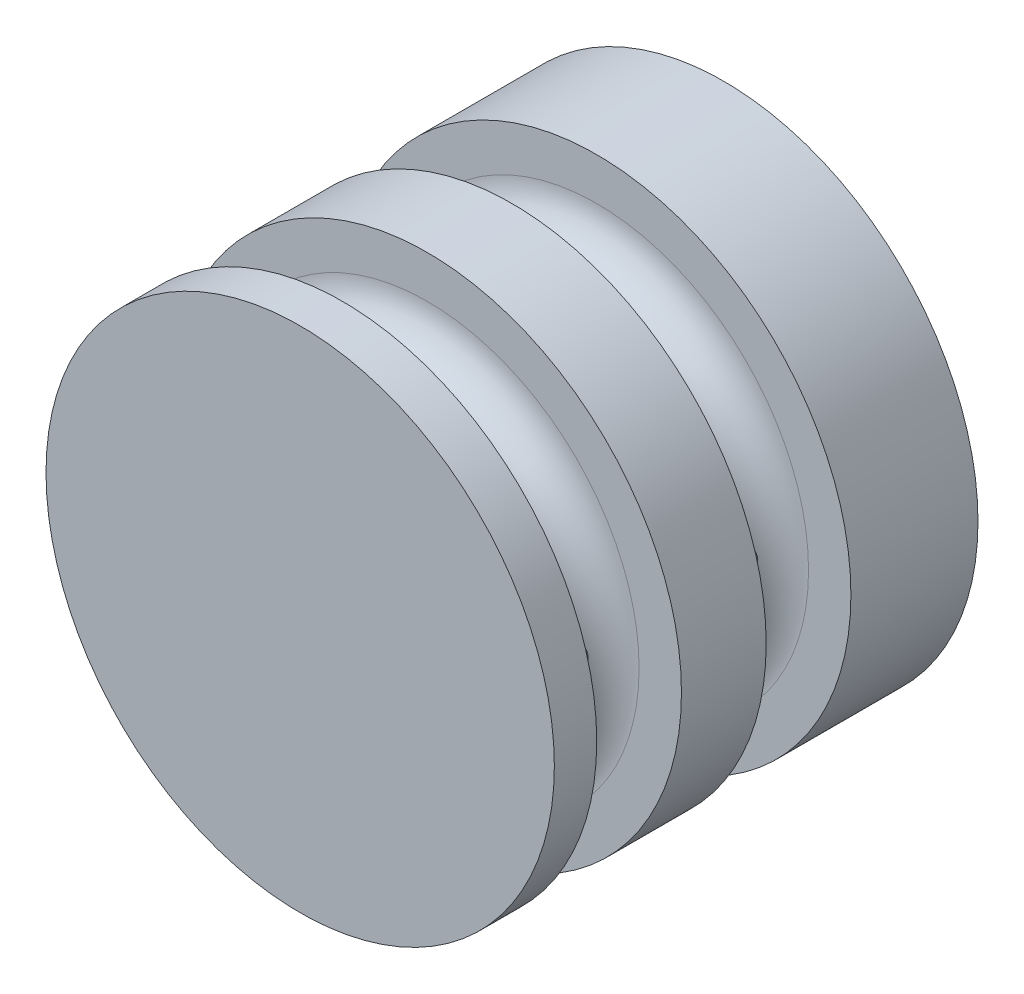
from build123d import *

# Parameters (mm, degrees)
SKETCH2_ONE_SIDE_W       = 5
SKETCH2_ONE_SIDE_H       = 15
SKETCH2_6_R              = 1.5
CUT_EXTRUDE1_DEPTH       = 16
CUT_EXTRUDE1_DEPTH_BACK  = 16
M3_CLEARANCE_HOLE1_D     = 3.2
M3_CLEARANCE_HOLE1_DEPTH = 5
M3_CLEARANCE_HOLE1_TIP   = 0.96137699
CUT_EXTRUDE2_START       = -25
SKETCH1_R                = 3.5
CUT_EXTRUDE2_DEPTH       = 5


with BuildPart() as part:
    # Sketch2 one side → Revolve5 (revolve)
    with BuildSketch(Plane(origin=(0, 0, 0), x_dir=(0, 0, -1), z_dir=(1, 0, 0))):
        with BuildLine():
            Line((3.5, 0), (6.5, 0))
            ThreePointArc((6.5, 0), (5, 1.5), (3.5, 0))
        make_face()
        with BuildLine():
            Line((13.5, 0), (16.5, 0))
            ThreePointArc((16.5, 0), (15, 1.5), (13.5, 0))
        make_face()
        with BuildLine():
            Line((2.5, 12.5), (2.5, 15))
            Line((2.5, 15), (0, 15))
            Line((0, 15), (0, 0))
            Line((0, 0), (3.5, 0))
            ThreePointArc((3.5, 0), (5, 1.5), (6.5, 0))
            Line((6.5, 0), (10, 0))
            Line((10, 0), (13.5, 0))
            ThreePointArc((13.5, 0), (15, 1.5), (16.5, 0))
            Line((16.5, 0), (20, 0))
            Line((20, 0), (20, 15))
            Line((20, 15), (17.5, 15))
            Line((17.5, 15), (17.5, 12.5))
            ThreePointArc((17.5, 12.5), (15, 10), (12.5, 12.5))
            Line((12.5, 12.5), (12.5, 15))
            Line((12.5, 15), (7.5, 15))
            Line((7.5, 15), (7.5, 12.5))
            ThreePointArc((7.5, 12.5), (5, 10), (2.5, 12.5))
        make_face()
        with Locations((22.5, 7.5)):
            Rectangle(SKETCH2_ONE_SIDE_W, SKETCH2_ONE_SIDE_H)
    revolve(axis=Axis((0, 0, 0), (0, 0, -1)))

    # Sketch2_6 → Cut-Extrude1 (cut, two sides)
    with BuildSketch(Plane(origin=(0, 0, 0), x_dir=(0, 0, -1), z_dir=(1, 0, 0))) as cut_extrude1_sk:
        with Locations((5, 0)):
            Circle(SKETCH2_6_R)
        with Locations((15, 0)):
            Circle(SKETCH2_6_R)
    extrude(amount=CUT_EXTRUDE1_DEPTH, mode=Mode.SUBTRACT)
    extrude(cut_extrude1_sk.sketch, amount=-CUT_EXTRUDE1_DEPTH_BACK, mode=Mode.SUBTRACT)

    # M3 Clearance Hole1
    with Locations(Plane(origin=(0, 0, -25), x_dir=(-1, 0, 0), z_dir=(0, 0, -1))):
        with Locations((0, 7), (7, 0), (0, -7), (-7, 0)):
            Hole(M3_CLEARANCE_HOLE1_D / 2, depth=M3_CLEARANCE_HOLE1_DEPTH)
            with Locations((0, 0, -(M3_CLEARANCE_HOLE1_DEPTH + M3_CLEARANCE_HOLE1_TIP / 2))):  # 118° drill point
                Cone(0, M3_CLEARANCE_HOLE1_D / 2, M3_CLEARANCE_HOLE1_TIP, mode=Mode.SUBTRACT)

    # Sketch1 → Cut-Extrude2 (cut)
    with BuildSketch(Plane.XY.offset(CUT_EXTRUDE2_START)):
        Circle(SKETCH1_R)
    extrude(amount=CUT_EXTRUDE2_DEPTH, mode=Mode.SUBTRACT)


solid = part.part
